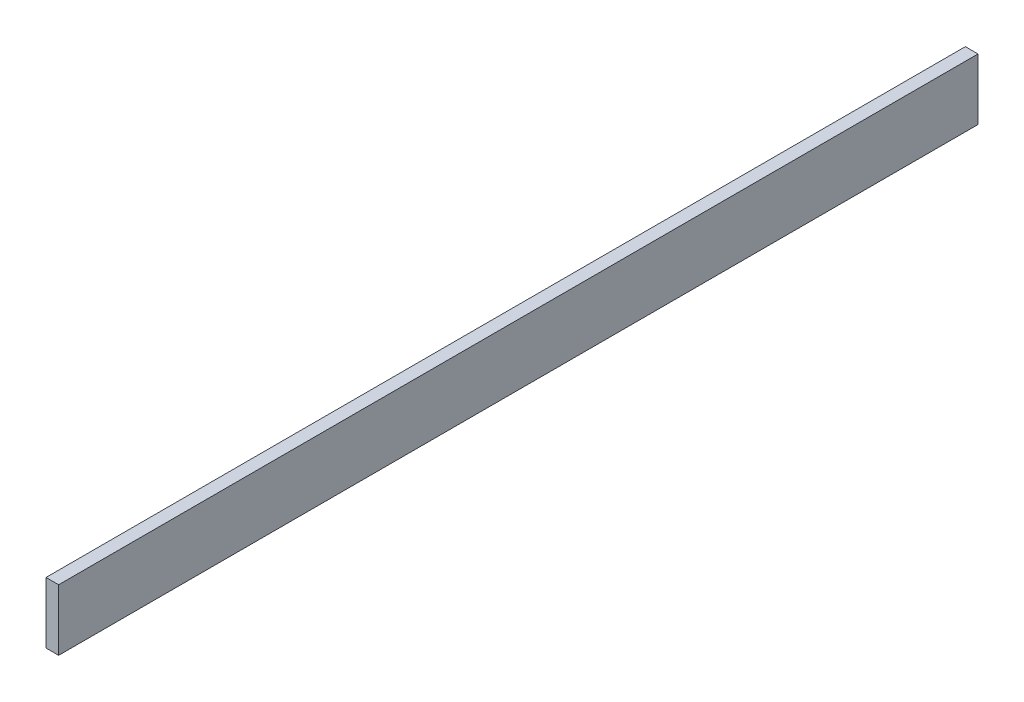
from build123d import *

# Parameters (mm, degrees)
SKETCH1_W           = 2768.6
SKETCH1_H           = 184.15
BOSS_EXTRUDE1_DEPTH = 38.1


with BuildPart() as part:
    # Sketch1 → Boss-Extrude1 (new body)
    with BuildSketch(Plane(origin=(0, 0, 0), x_dir=(0, 0, -1), z_dir=(1, 0, 0))):
        with Locations((910.128181818, 142.875)):
            Rectangle(SKETCH1_W, SKETCH1_H)
    extrude(amount=BOSS_EXTRUDE1_DEPTH)


solid = part.part
